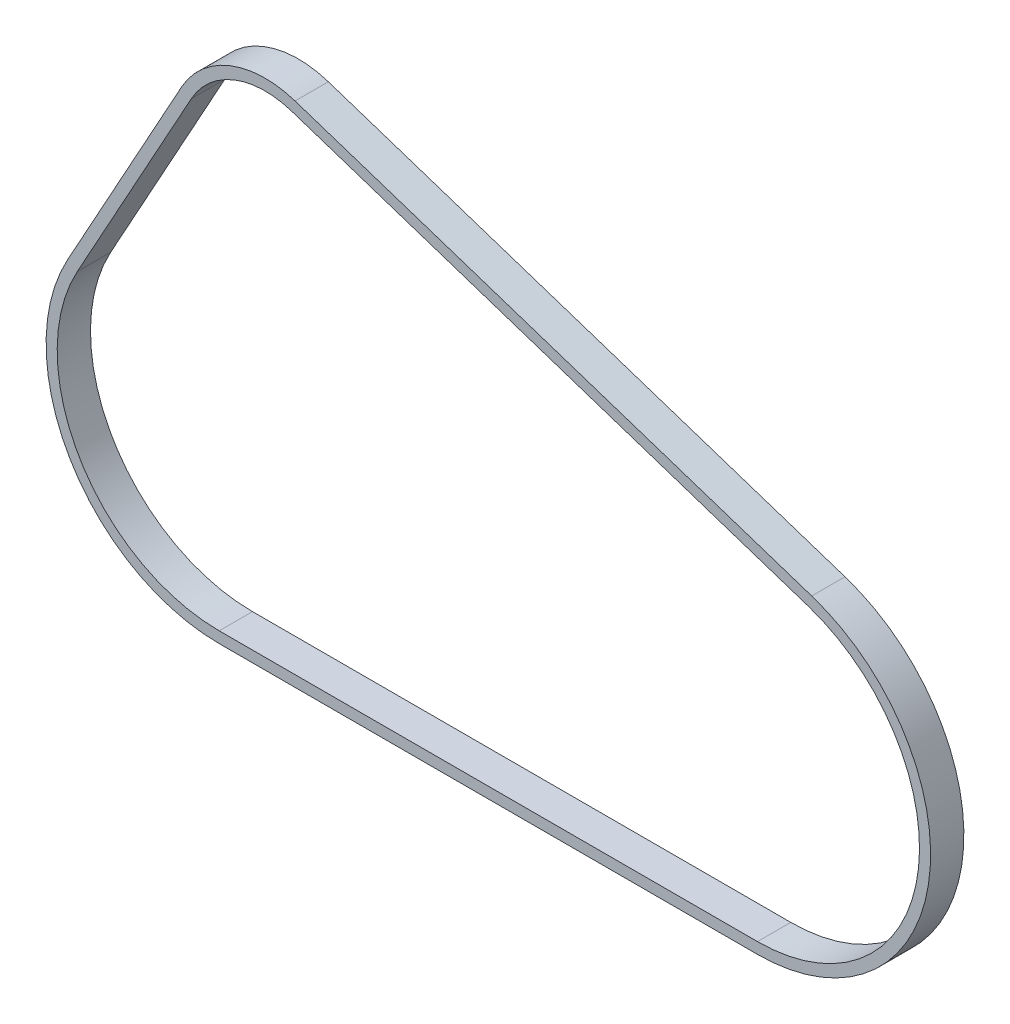
from build123d import *

# Parameters (mm, degrees)
EXTRUDE_THIN1_DEPTH      = 7.5
EXTRUDE_THIN1_DEPTH_BACK = 7.5


with BuildPart() as part:
    # Sketch2 → Extrude-Thin1 (new, two sides)
    with BuildSketch(Plane.XY) as extrude_thin1_sk:
        with BuildLine():
            Line((246.24621437, -35.923587532), (13.466243252, 40.836996617))
            ThreePointArc((13.466243252, 40.836996617), (-15.71191081, 40.02668933), (-37.64999876, 20.772038739))
            Line((-37.64999876, 20.772038739), (-89.010467091, -72.320487869))
            ThreePointArc((-89.010467091, -72.320487869), (-87.882828318, -149.654747848), (-20.715120503, -188))
            Line((-20.715120503, -188), (221.819075448, -188))
            ThreePointArc((221.819075448, -188), (298.831932078, -122.370121817), (246.24621437, -35.923587532))
        make_face()
        with BuildLine():
            Line((244.680372131, -40.672075511), (11.900401013, 36.088508638))
            ThreePointArc((11.900401013, 36.088508638), (-13.884944436, 35.372423129), (-33.272091928, 18.356685397))
            Line((-33.272091928, 18.356685397), (-84.632560259, -74.735841211))
            ThreePointArc((-84.632560259, -74.735841211), (-83.577206022, -147.112776832), (-20.715120503, -183))
            Line((-20.715120503, -183), (221.819075448, -183))
            ThreePointArc((221.819075448, -183), (293.895210499, -121.57716529), (244.680372131, -40.672075511))
        make_face(mode=Mode.SUBTRACT)
    extrude(amount=EXTRUDE_THIN1_DEPTH)
    extrude(extrude_thin1_sk.sketch, amount=-EXTRUDE_THIN1_DEPTH_BACK)


solid = part.part
